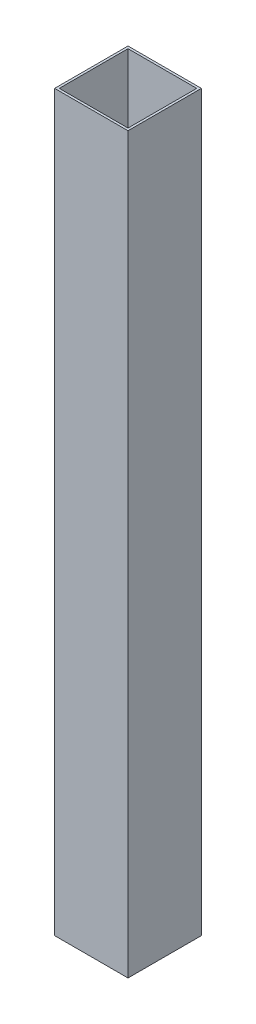
from build123d import *

# Parameters (mm, degrees)
SKETCH1_W           = 50.8
SKETCH1_H           = 50.8
SKETCH1_W_2         = 47.5996
SKETCH1_H_2         = 47.5996
BOSS_EXTRUDE1_DEPTH = 508


with BuildPart() as part:
    # Sketch1 → Boss-Extrude1 (new body)
    with BuildSketch(Plane(origin=(0, 0, 0), x_dir=(1, 0, 0), z_dir=(0, 1, 0))):
        with Locations((25.4, 25.4)):
            Rectangle(SKETCH1_W, SKETCH1_H)
        with Locations((25.4, 25.4)):
            Rectangle(SKETCH1_W_2, SKETCH1_H_2, mode=Mode.SUBTRACT)
    extrude(amount=BOSS_EXTRUDE1_DEPTH)


solid = part.part
